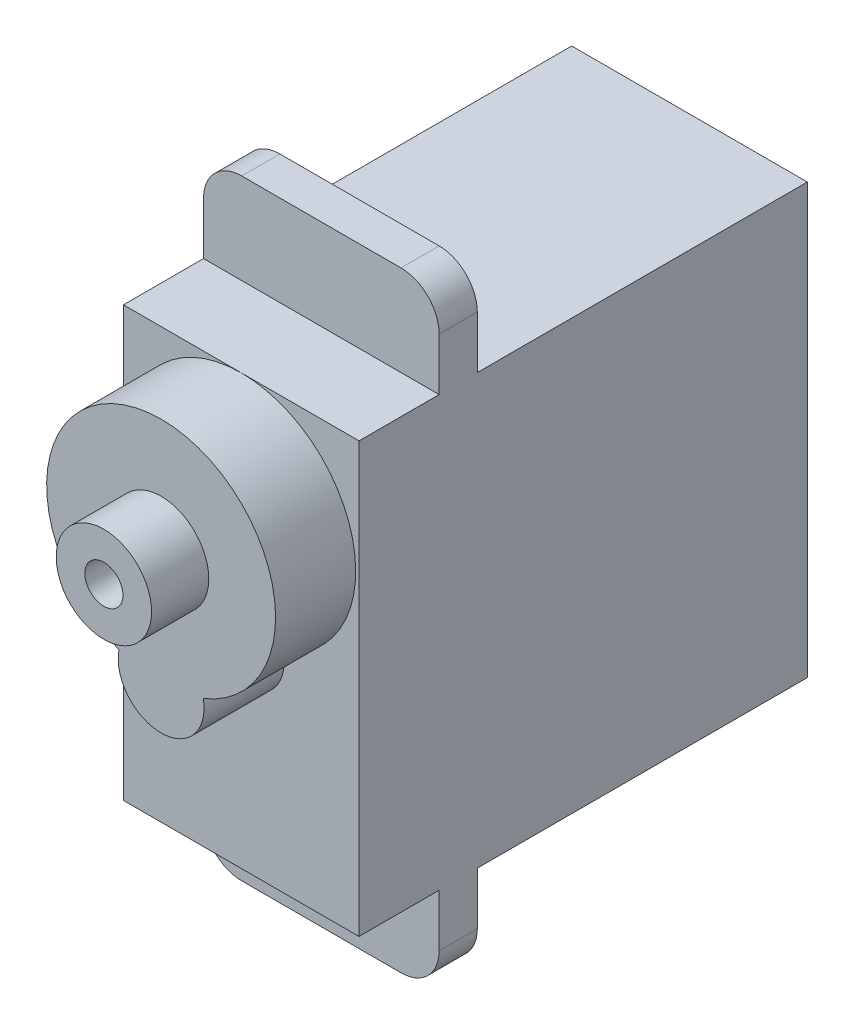
from build123d import *

# Parameters (mm, degrees)
SKETCH3_W           = 22.5
SKETCH3_H           = 23.5
BOSS_EXTRUDE1_DEPTH = 6.175
SKETCH4_W           = 12.35
SKETCH4_H           = 32
BOSS_EXTRUDE2_DEPTH = 2
BOSS_EXTRUDE3_DEPTH = 4.2
SKETCH6_R           = 2.5
CUT_EXTRUDE1_DEPTH  = 4.2
FILLET1_R           = 2
SKETCH7_R           = 2.5
BOSS_EXTRUDE4_DEPTH = 7.2
SKETCH8_R           = 1
CUT_EXTRUDE2_DEPTH  = 7


with BuildPart() as part:
    # Sketch3 → Boss-Extrude1 (new body, symmetric)
    with BuildSketch(Plane(origin=(0, -28.275548605, 0), x_dir=(0, 1, 0), z_dir=(1, 0, 0))):
        with Locations((24.609729517, 167.116706922)):
            Rectangle(SKETCH3_W, SKETCH3_H)
    extrude(amount=BOSS_EXTRUDE1_DEPTH, both=True)

    # Sketch4 → Boss-Extrude2 (add)
    with BuildSketch(Plane.XY.offset(174.666706922)):
        with Locations((0, -3.665819089)):
            Rectangle(SKETCH4_W, SKETCH4_H)
    extrude(amount=-BOSS_EXTRUDE2_DEPTH)

    # Sketch5 → Boss-Extrude3 (add)
    with BuildSketch(Plane.XY.offset(178.866706922)):
        with BuildLine():
            ThreePointArc((2.210095356, -3.993944089), (0, 7.584180911), (-2.210095356, -3.993944089))
            ThreePointArc((-2.210095356, -3.993944089), (0, -6.665819089), (2.210095356, -3.993944089))
        make_face()
    extrude(amount=BOSS_EXTRUDE3_DEPTH)

    # Sketch6 → Cut-Extrude1 (cut)
    with BuildSketch(Plane.XY.offset(183.066706922)):
        with Locations((0, 1.584180911)):
            Circle(SKETCH6_R)
    extrude(amount=-CUT_EXTRUDE1_DEPTH, mode=Mode.SUBTRACT)

    # Fillet1
    fillet1_edges = [part.edges().sort_by_distance(p)[0] for p in [
        (-6.175, -19.665819089, 173.666706922),
        (6.175, 12.334180911, 173.666706922),
        (-6.175, 12.334180911, 173.666706922),
        (6.175, -19.665819089, 173.666706922),
    ]]
    fillet(fillet1_edges, radius=FILLET1_R)

    # Sketch7 → Boss-Extrude4 (add)
    with BuildSketch(Plane.XY.offset(178.866706922)):
        with Locations((0, 1.584180911)):
            Circle(SKETCH7_R)
    extrude(amount=BOSS_EXTRUDE4_DEPTH)

    # Sketch8 → Cut-Extrude2 (cut)
    with BuildSketch(Plane.XY.offset(186.066706922)):
        with Locations((0, 1.584180911)):
            Circle(SKETCH8_R)
    extrude(amount=-CUT_EXTRUDE2_DEPTH, mode=Mode.SUBTRACT)


solid = part.part
